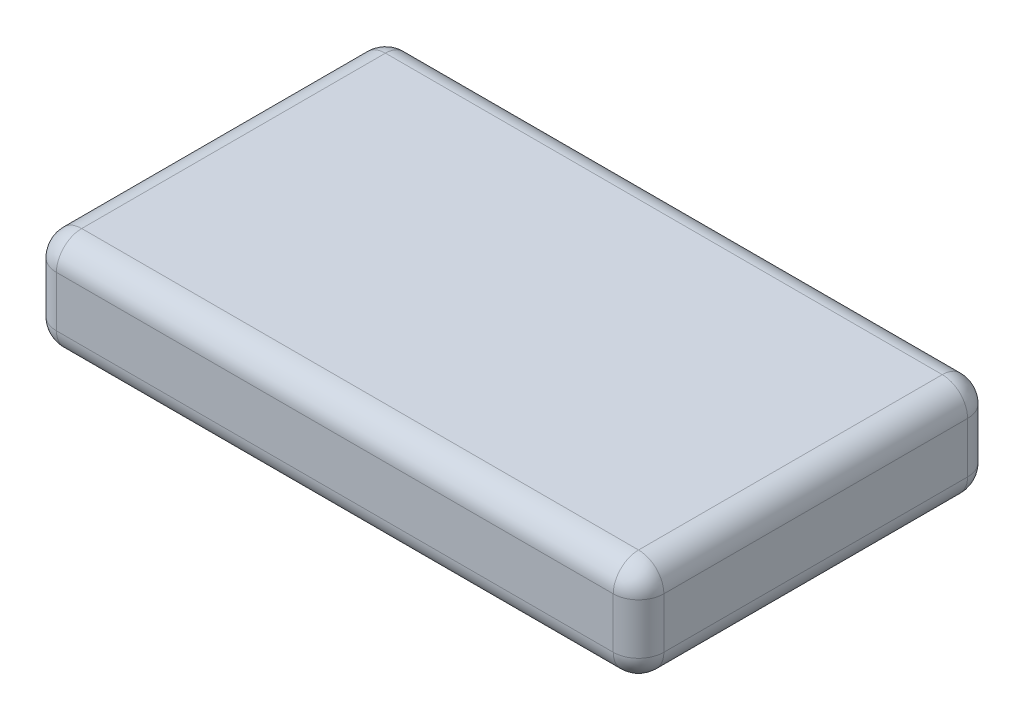
from build123d import *

# Parameters (mm, degrees)
SKETCH1_W           = 609.6
SKETCH1_H           = 355.6
BOSS_EXTRUDE1_DEPTH = 101.6
FILLET1_R           = 25.4


with BuildPart() as part:
    # Sketch1 → Boss-Extrude1 (new body)
    with BuildSketch(Plane(origin=(0, 0, 0), x_dir=(1, 0, 0), z_dir=(0, 1, 0))):
        with Locations((304.8, 177.8)):
            Rectangle(SKETCH1_W, SKETCH1_H)
    extrude(amount=BOSS_EXTRUDE1_DEPTH)

    # Fillet1
    fillet1_edges = [part.edges().sort_by_distance(p)[0] for p in [
        (609.6, 101.6, -177.8),
        (304.8, 101.6, -355.6),
        (0, 101.6, -177.8),
        (304.8, 0, -355.6),
        (609.6, 0, -177.8),
        (304.8, 0, 0),
        (0, 0, -177.8),
        (304.8, 101.6, 0),
        (0, 50.8, -355.6),
        (609.6, 50.8, -355.6),
        (609.6, 50.8, 0),
        (0, 50.8, 0),
    ]]
    fillet(fillet1_edges, radius=FILLET1_R)


solid = part.part
